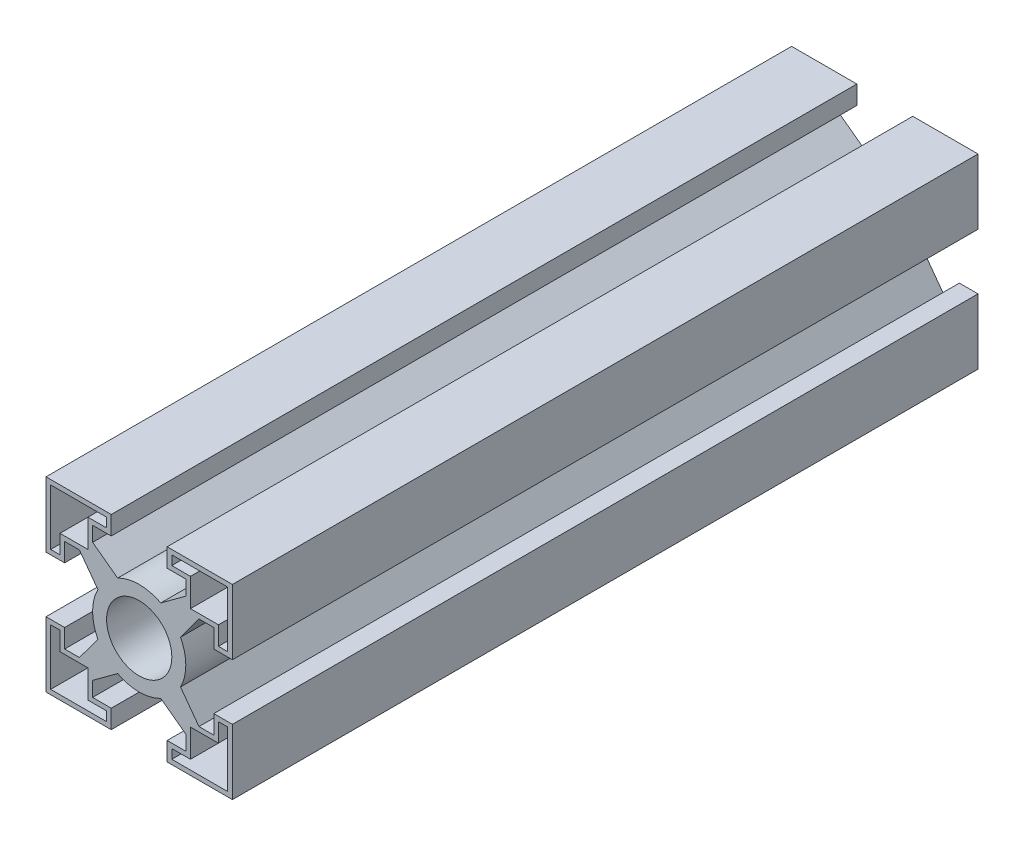
from build123d import *

# Parameters (mm, degrees)
ESQUISSE1_R        = 1.75
BOSS_EXTRU_1_DEPTH = 40


with BuildPart() as part:
    # Esquisse1 → Boss.-Extru.1 (new body)
    with BuildSketch(Plane.XY):
        with BuildLine():
            Line((-1.5, 5), (-5, 5))
            Line((-5, 5), (-5, 1.5))
            Line((-5, 1.5), (-4, 1.5))
            Line((-4, 1.5), (-4, 2.5))
            Line((-4, 2.5), (-3.207106781, 2.5))
            Line((-3.207106781, 2.5), (-2.216672281, 1.15601211))
            ThreePointArc((-2.216672281, 1.15601211), (-2.5, 0), (-2.216672281, -1.15601211))
            Line((-2.216672281, -1.15601211), (-3.207106781, -2.5))
            Line((-3.207106781, -2.5), (-4, -2.5))
            Line((-4, -2.5), (-4, -1.5))
            Line((-4, -1.5), (-5, -1.5))
            Line((-5, -1.5), (-5, -5))
            Line((-5, -5), (-1.5, -5))
            Line((-1.5, -5), (-1.5, -4))
            Line((-1.5, -4), (-2.5, -4))
            Line((-2.5, -4), (-2.5, -3.207106781))
            Line((-2.5, -3.207106781), (-1.15601211, -2.216672281))
            ThreePointArc((-1.15601211, -2.216672281), (0, -2.5), (1.15601211, -2.216672281))
            Line((1.15601211, -2.216672281), (2.5, -3.207106781))
            Line((2.5, -3.207106781), (2.5, -4))
            Line((2.5, -4), (1.5, -4))
            Line((1.5, -4), (1.5, -5))
            Line((1.5, -5), (5, -5))
            Line((5, -5), (5, -1.5))
            Line((5, -1.5), (4, -1.5))
            Line((4, -1.5), (4, -2.5))
            Line((4, -2.5), (3.207106781, -2.5))
            Line((3.207106781, -2.5), (2.216672281, -1.15601211))
            ThreePointArc((2.216672281, -1.15601211), (2.5, 0), (2.216672281, 1.15601211))
            Line((2.216672281, 1.15601211), (3.207106781, 2.5))
            Line((3.207106781, 2.5), (4, 2.5))
            Line((4, 2.5), (4, 1.5))
            Line((4, 1.5), (5, 1.5))
            Line((5, 1.5), (5, 5))
            Line((5, 5), (1.5, 5))
            Line((1.5, 5), (1.5, 4))
            Line((1.5, 4), (2.5, 4))
            Line((2.5, 4), (2.5, 3.207106781))
            Line((2.5, 3.207106781), (1.15601211, 2.216672281))
            ThreePointArc((1.15601211, 2.216672281), (0, 2.5), (-1.15601211, 2.216672281))
            Line((-1.15601211, 2.216672281), (-2.5, 3.207106781))
            Line((-2.5, 3.207106781), (-2.5, 4))
            Line((-2.5, 4), (-1.5, 4))
            Line((-1.5, 4), (-1.5, 5))
        make_face()
        Polygon((-4.75, 1.75), (-4.75, 4.75), (-1.75, 4.75), (-1.75, 4.25), (-2.75, 4.25), (-2.75, 2.75), (-4.25, 2.75), (-4.25, 1.75), align=None, mode=Mode.SUBTRACT)
        Circle(ESQUISSE1_R, mode=Mode.SUBTRACT)
        Polygon((-4.75, -4.75), (-4.75, -1.75), (-4.25, -1.75), (-4.25, -2.75), (-2.75, -2.75), (-2.75, -4.25), (-1.75, -4.25), (-1.75, -4.75), align=None, mode=Mode.SUBTRACT)
        Polygon((4.75, 4.75), (4.75, 1.75), (4.25, 1.75), (4.25, 2.75), (2.75, 2.75), (2.75, 4.25), (1.75, 4.25), (1.75, 4.75), align=None, mode=Mode.SUBTRACT)
        Polygon((4.75, -4.75), (1.75, -4.75), (1.75, -4.25), (2.75, -4.25), (2.75, -2.75), (4.25, -2.75), (4.25, -1.75), (4.75, -1.75), align=None, mode=Mode.SUBTRACT)
    extrude(amount=BOSS_EXTRU_1_DEPTH)


solid = part.part
